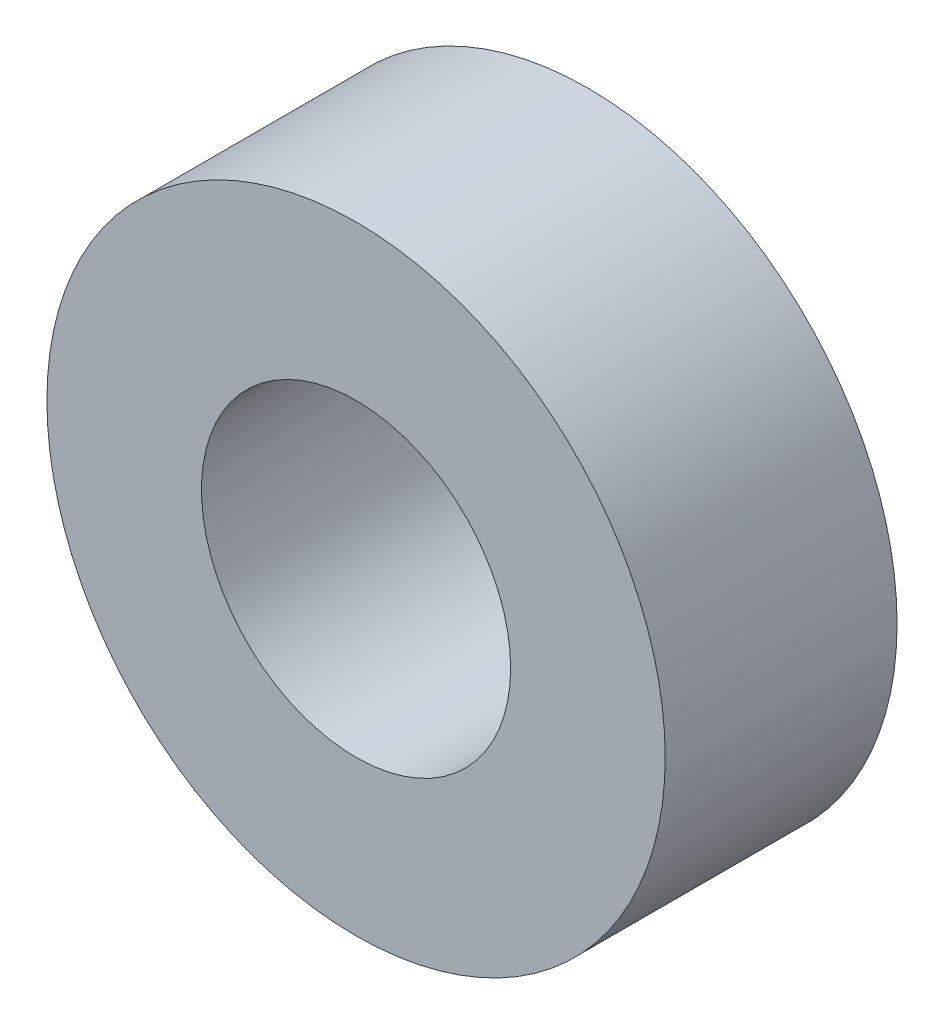
from build123d import *

# Parameters (mm, degrees)
ESQUISSE1_R      = 4
ESQUISSE1_R_2    = 2
EXTRUSION1_DEPTH = 3


with BuildPart() as part:
    # Esquisse1 → Extrusion1 (new body)
    with BuildSketch(Plane.XY):
        Circle(ESQUISSE1_R)
        Circle(ESQUISSE1_R_2, mode=Mode.SUBTRACT)
    extrude(amount=EXTRUSION1_DEPTH)


solid = part.part
